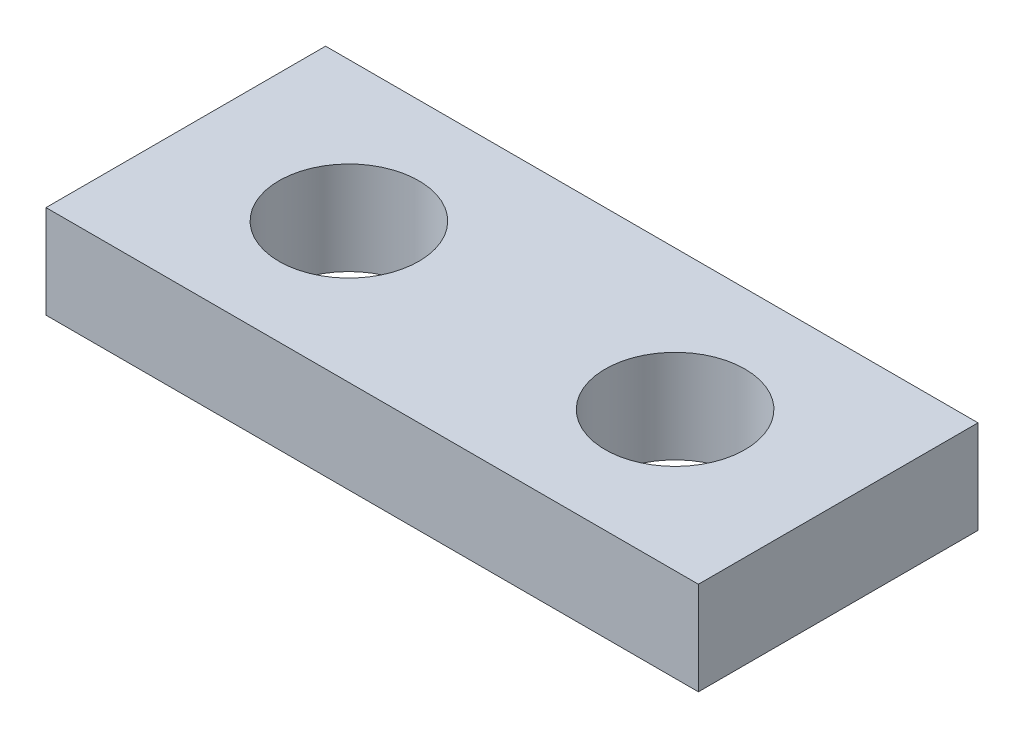
from build123d import *

# Parameters (mm, degrees)
SKETCH1_W           = 14
SKETCH1_H           = 6
SKETCH1_R           = 1.5
BOSS_EXTRUDE1_DEPTH = 2


with BuildPart() as part:
    # Sketch1 → Boss-Extrude1 (new body)
    with BuildSketch(Plane(origin=(0, 0, 0), x_dir=(1, 0, 0), z_dir=(0, 1, 0))):
        with Locations((7, 3)):
            Rectangle(SKETCH1_W, SKETCH1_H)
        with Locations((3.5, 3)):
            Circle(SKETCH1_R, mode=Mode.SUBTRACT)
        with Locations((10.5, 3)):
            Circle(SKETCH1_R, mode=Mode.SUBTRACT)
    extrude(amount=BOSS_EXTRUDE1_DEPTH)


solid = part.part
